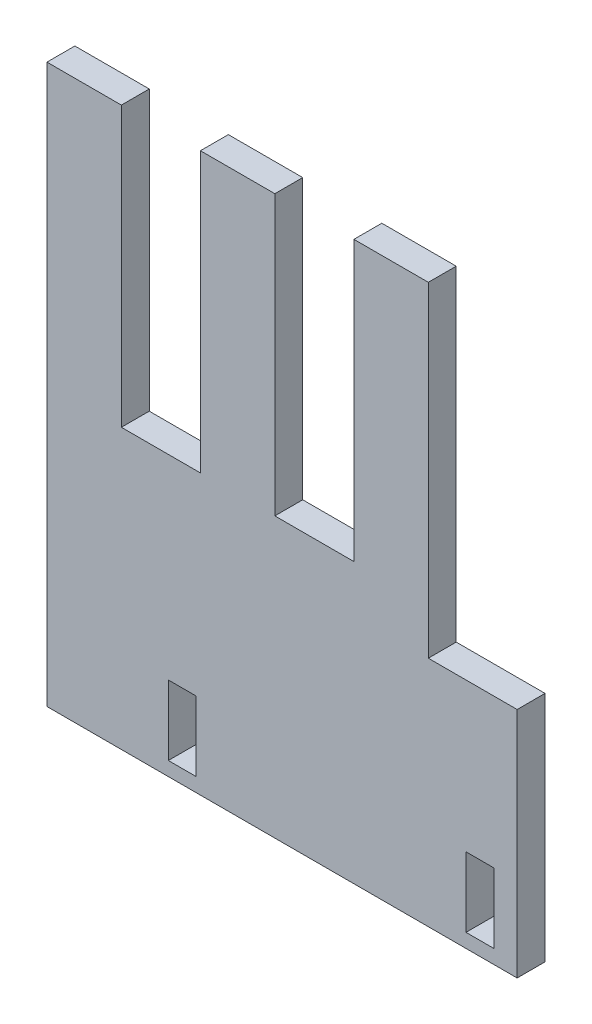
from build123d import *

# Parameters (mm, degrees)
ESQUISSE1_W        = 6
ESQUISSE1_H        = 15
BOSS_EXTRU_1_DEPTH = 6


with BuildPart() as part:
    # Esquisse1 → Boss.-Extru.1 (new body)
    with BuildSketch(Plane.XY):
        Polygon((25.167583758, 47.381284916), (25.167583758, -12.618715084), (8.167583758, -12.618715084), (8.167583758, 47.381284916), (-7.832416242, 47.381284916), (-7.832416242, -12.618715084), (-24.832416242, -12.618715084), (-24.832416242, 47.381284916), (-40.832416242, 47.381284916), (-40.832416242, -72.618715084), (60.267583758, -72.618715084), (60.267583758, -22.618715084), (41.167583758, -22.618715084), (41.167583758, 47.381284916), align=None)
        with Locations((52.267583758, -62.118715084)):
            Rectangle(ESQUISSE1_W, ESQUISSE1_H, mode=Mode.SUBTRACT)
        with Locations((-11.732416242, -62.118715084)):
            Rectangle(ESQUISSE1_W, ESQUISSE1_H, mode=Mode.SUBTRACT)
    extrude(amount=BOSS_EXTRU_1_DEPTH)


solid = part.part
